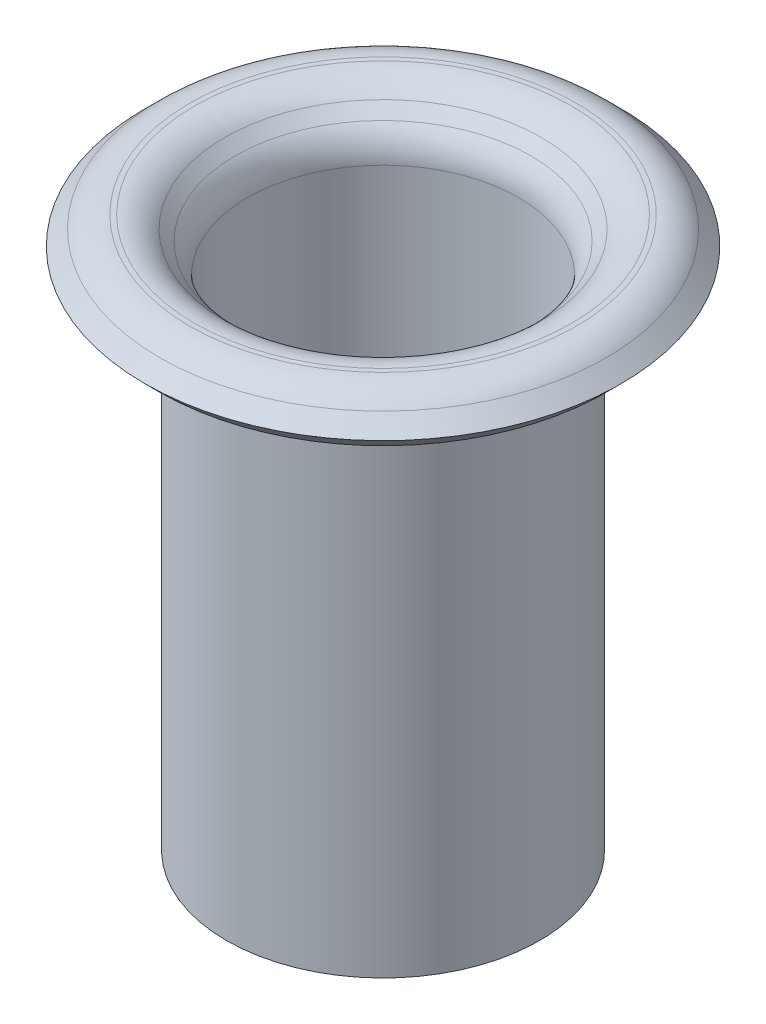
from build123d import *


with BuildPart() as part:
    # Esquisse1 → Révolution1 (revolve)
    with BuildSketch(Plane.XY):
        with BuildLine():
            Line((-1.497157288, -0.117157288), (-1.397157288, -0.217157288))
            ThreePointArc((-1.397157288, -0.217157288), (-1.310448187, -0.346926627), (-1.28, -0.5))
            Line((-1.28, -0.5), (-1.28, -5.2))
            Line((-1.28, -5.2), (-1.48, -5.2))
            Line((-1.48, -5.2), (-1.48, -0.5))
            ThreePointArc((-1.48, -0.5), (-1.495224093, -0.423463314), (-1.538578644, -0.358578644))
            Line((-1.538578644, -0.358578644), (-1.638578644, -0.258578644))
            ThreePointArc((-1.638578644, -0.258578644), (-1.703463314, -0.215224093), (-1.78, -0.2))
            Line((-1.78, -0.2), (-1.825735931, -0.2))
            ThreePointArc((-1.825735931, -0.2), (-1.902272618, -0.215224093), (-1.967157288, -0.258578644))
            Line((-1.967157288, -0.258578644), (-2.108578644, -0.4))
            Line((-2.108578644, -0.4), (-2.25, -0.258578644))
            Line((-2.25, -0.258578644), (-2.108578644, -0.117157288))
            ThreePointArc((-2.108578644, -0.117157288), (-1.978809304, -0.030448187), (-1.825735931, 0))
            Line((-1.825735931, 0), (-1.78, 0))
            ThreePointArc((-1.78, 0), (-1.626926627, -0.030448187), (-1.497157288, -0.117157288))
        make_face()
    revolve(axis=Axis((0, 0, 0), (0, -1, 0)))


solid = part.part
